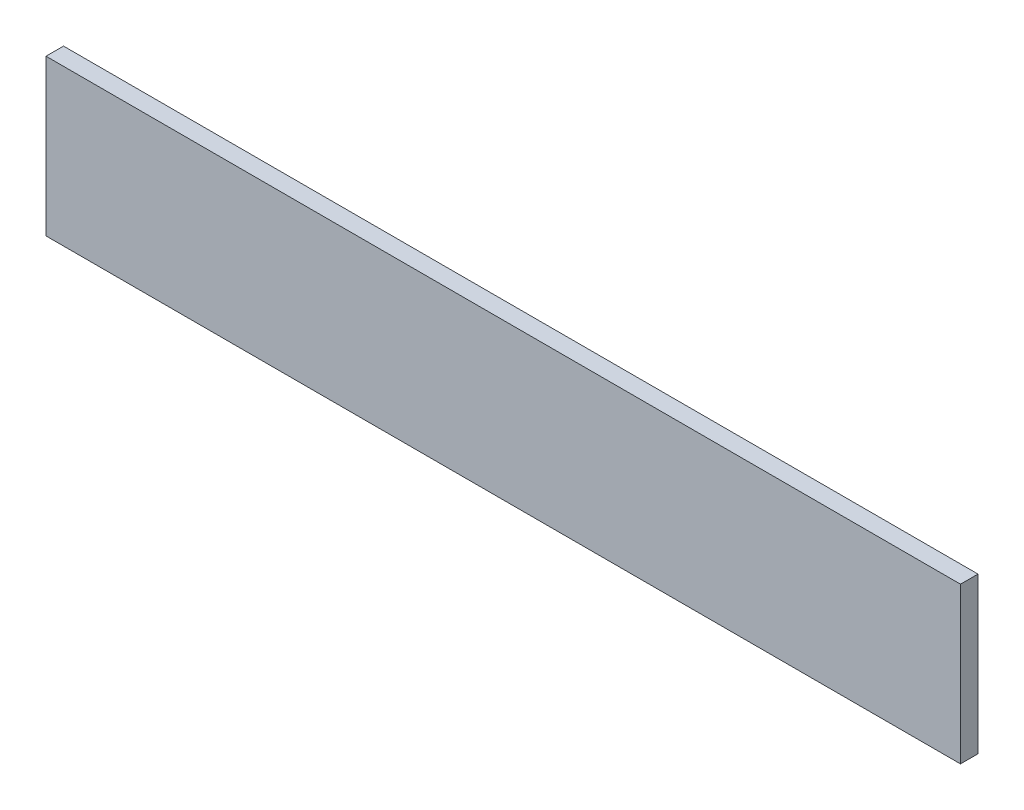
from build123d import *

# Parameters (mm, degrees)
SZKIC1_W                    = 470
SZKIC1_H                    = 80
DODANIE_WYCI_GNI_CIE1_DEPTH = 9


with BuildPart() as part:
    # Szkic1 → Dodanie-wyciągnięcie1 (new body)
    with BuildSketch(Plane.XY):
        with Locations((235, 40)):
            Rectangle(SZKIC1_W, SZKIC1_H)
    extrude(amount=-DODANIE_WYCI_GNI_CIE1_DEPTH)


solid = part.part
